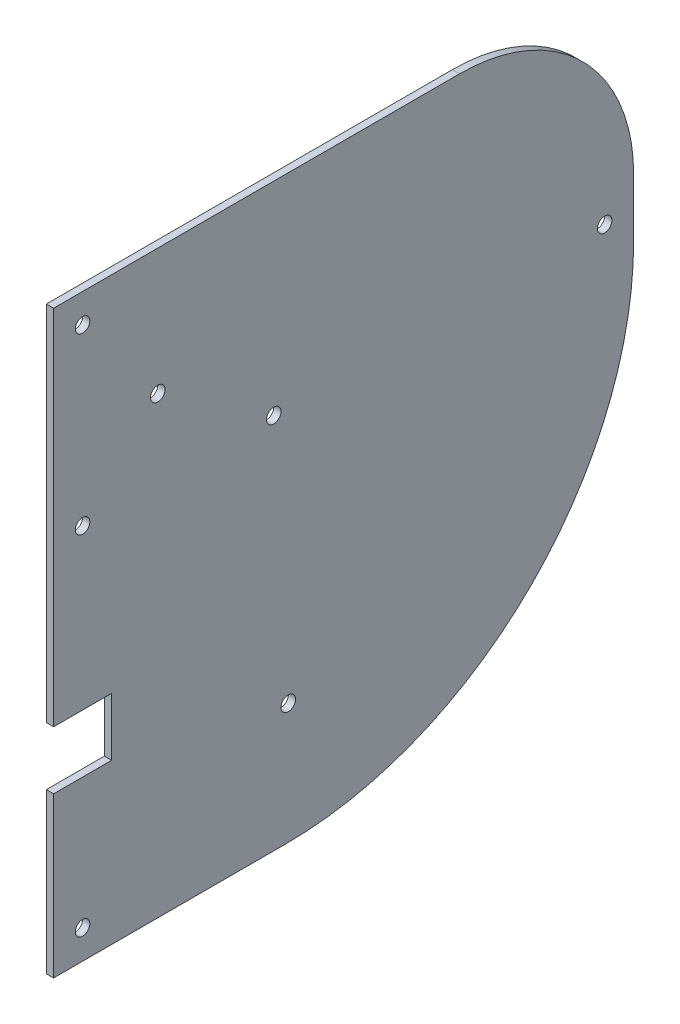
from build123d import *

# Parameters (mm, degrees)
SKETCH1_W           = 254
SKETCH1_H           = 254
BOSS_EXTRUDE1_DEPTH = 3.175
SKETCH2_R           = 3.175
SKETCH2_W           = 25.4
SKETCH2_H           = 25.4
CUT_EXTRUDE1_DEPTH  = 4.175
FILLET1_R           = 152.4
FILLET2_R           = 76.2


with BuildPart() as part:
    # Sketch1 → Boss-Extrude1 (new body)
    with BuildSketch(Plane(origin=(0, 0, 0), x_dir=(0, 0, -1), z_dir=(1, 0, 0))):
        with Locations((127, 127)):
            Rectangle(SKETCH1_W, SKETCH1_H)
    extrude(amount=BOSS_EXTRUDE1_DEPTH)

    # Sketch2 → Cut-Extrude1 (cut, through all)
    with BuildSketch(Plane(origin=(3.175, 0, 0), x_dir=(0, 0, -1), z_dir=(1, 0, 0))):
        with Locations((102.775, 52.775)):
            Circle(SKETCH2_R)
        with Locations((96.425, 165.10000014)):
            Circle(SKETCH2_R)
        with Locations((45.625, 198.825)):
            Circle(SKETCH2_R)
        with Locations((12.7, 165.1)):
            Circle(SKETCH2_R)
        with Locations((12.7, 241.3)):
            Circle(SKETCH2_R)
        with Locations((12.7, 12.7)):
            Circle(SKETCH2_R)
        with Locations((241.3, 165.1)):
            Circle(SKETCH2_R)
        with Locations((12.7, 82.55)):
            Rectangle(SKETCH2_W, SKETCH2_H)
    extrude(amount=-CUT_EXTRUDE1_DEPTH, mode=Mode.SUBTRACT)

    # Fillet1
    fillet1_edges = [part.edges().sort_by_distance(p)[0] for p in [
        (1.5875, 0, -254),
    ]]
    fillet(fillet1_edges, radius=FILLET1_R)

    # Fillet2
    fillet2_edges = [part.edges().sort_by_distance(p)[0] for p in [
        (1.5875, 254, -254),
    ]]
    fillet(fillet2_edges, radius=FILLET2_R)


solid = part.part
